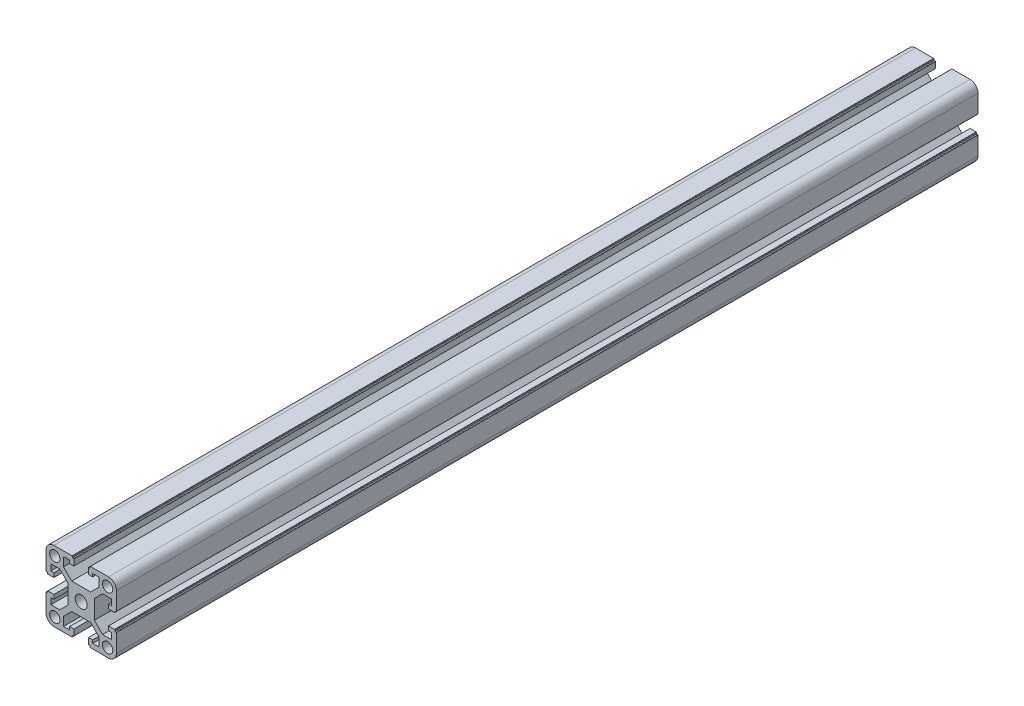
from build123d import *

# Parameters (mm, degrees)
SKETCH_1_R          = 2.95
SKETCH_1_R_2        = 3.4
EXTRUDE_1_DEPTH     = 245
SKETCH_2_R          = 4
CUT_EXTRUDE_1_DEPTH = 49


with BuildPart() as part:
    # 草图1 → 凸台-拉伸1 (new body, symmetric)
    with BuildSketch(Plane.XY.offset(100)):
        with BuildLine():
            Line((-1518.245004392, 3588.004280474), (-1518.245004392, 3582.975600817))
            Line((-1518.245004392, 3582.975600817), (-1522.916324736, 3578.304280474))
            Line((-1522.916324736, 3578.304280474), (-1533.673684048, 3578.304280474))
            Line((-1533.673684048, 3578.304280474), (-1538.345004392, 3582.975600817))
            Line((-1538.345004392, 3582.975600817), (-1538.345004392, 3588.004280474))
            Line((-1538.345004392, 3588.004280474), (-1534.845004392, 3588.004280474))
            Line((-1534.845004392, 3588.004280474), (-1534.845004392, 3586.304280474))
            Line((-1534.845004392, 3586.304280474), (-1532.445004392, 3586.304280474))
            Line((-1532.445004392, 3586.304280474), (-1532.445004392, 3589.704280474))
            ThreePointArc((-1532.445004392, 3589.704280474), (-1532.503583036, 3589.84570183), (-1532.645004392, 3589.904280474))
            Line((-1532.645004392, 3589.904280474), (-1533.345004392, 3589.904280474))
            Line((-1533.345004392, 3589.904280474), (-1533.345004392, 3590.604280474))
            ThreePointArc((-1533.345004392, 3590.604280474), (-1533.403583036, 3590.74570183), (-1533.545004392, 3590.804280474))
            Line((-1533.545004392, 3590.804280474), (-1543.795004392, 3590.804280474))
            ThreePointArc((-1543.795004392, 3590.804280474), (-1546.976984907, 3589.486260989), (-1548.295004392, 3586.304280474))
            Line((-1548.295004392, 3586.304280474), (-1548.295004392, 3576.054280474))
            ThreePointArc((-1548.295004392, 3576.054280474), (-1548.236425748, 3575.912859117), (-1548.095004392, 3575.854280474))
            Line((-1548.095004392, 3575.854280474), (-1547.395004392, 3575.854280474))
            Line((-1547.395004392, 3575.854280474), (-1547.395004392, 3575.154280474))
            ThreePointArc((-1547.395004392, 3575.154280474), (-1547.336425748, 3575.012859117), (-1547.195004392, 3574.954280474))
            Line((-1547.195004392, 3574.954280474), (-1543.795004392, 3574.954280474))
            Line((-1543.795004392, 3574.954280474), (-1543.795004392, 3577.354280474))
            Line((-1543.795004392, 3577.354280474), (-1545.495004392, 3577.354280474))
            Line((-1545.495004392, 3577.354280474), (-1545.495004392, 3580.854280474))
            Line((-1545.495004392, 3580.854280474), (-1540.466324736, 3580.854280474))
            Line((-1540.466324736, 3580.854280474), (-1535.795004392, 3576.18296013))
            Line((-1535.795004392, 3576.18296013), (-1535.795004392, 3565.425600817))
            Line((-1535.795004392, 3565.425600817), (-1540.466324736, 3560.754280474))
            Line((-1540.466324736, 3560.754280474), (-1545.495004392, 3560.754280474))
            Line((-1545.495004392, 3560.754280474), (-1545.495004392, 3564.254280474))
            Line((-1545.495004392, 3564.254280474), (-1543.795004392, 3564.254280474))
            Line((-1543.795004392, 3564.254280474), (-1543.795004392, 3566.654280474))
            Line((-1543.795004392, 3566.654280474), (-1547.195004392, 3566.654280474))
            ThreePointArc((-1547.195004392, 3566.654280474), (-1547.336425748, 3566.59570183), (-1547.395004392, 3566.454280474))
            Line((-1547.395004392, 3566.454280474), (-1547.395004392, 3565.754280474))
            Line((-1547.395004392, 3565.754280474), (-1548.095004392, 3565.754280474))
            ThreePointArc((-1548.095004392, 3565.754280474), (-1548.236425748, 3565.69570183), (-1548.295004392, 3565.554280474))
            Line((-1548.295004392, 3565.554280474), (-1548.295004392, 3555.304280474))
            ThreePointArc((-1548.295004392, 3555.304280474), (-1546.976984907, 3552.122299958), (-1543.795004392, 3550.804280474))
            Line((-1543.795004392, 3550.804280474), (-1533.545004392, 3550.804280474))
            ThreePointArc((-1533.545004392, 3550.804280474), (-1533.403583036, 3550.862859117), (-1533.345004392, 3551.004280474))
            Line((-1533.345004392, 3551.004280474), (-1533.345004392, 3551.704280474))
            Line((-1533.345004392, 3551.704280474), (-1532.645004392, 3551.704280474))
            ThreePointArc((-1532.645004392, 3551.704280474), (-1532.503583036, 3551.762859117), (-1532.445004392, 3551.904280474))
            Line((-1532.445004392, 3551.904280474), (-1532.445004392, 3555.304280474))
            Line((-1532.445004392, 3555.304280474), (-1534.845004392, 3555.304280474))
            Line((-1534.845004392, 3555.304280474), (-1534.845004392, 3553.604280474))
            Line((-1534.845004392, 3553.604280474), (-1538.345004392, 3553.604280474))
            Line((-1538.345004392, 3553.604280474), (-1538.345004392, 3558.63296013))
            Line((-1538.345004392, 3558.63296013), (-1533.673684048, 3563.304280474))
            Line((-1533.673684048, 3563.304280474), (-1522.916324736, 3563.304280474))
            Line((-1522.916324736, 3563.304280474), (-1518.245004392, 3558.63296013))
            Line((-1518.245004392, 3558.63296013), (-1518.245004392, 3553.604280474))
            Line((-1518.245004392, 3553.604280474), (-1521.745004392, 3553.604280474))
            Line((-1521.745004392, 3553.604280474), (-1521.745004392, 3555.304280474))
            Line((-1521.745004392, 3555.304280474), (-1524.145004392, 3555.304280474))
            Line((-1524.145004392, 3555.304280474), (-1524.145004392, 3551.904280474))
            ThreePointArc((-1524.145004392, 3551.904280474), (-1524.086425748, 3551.762859117), (-1523.945004392, 3551.704280474))
            Line((-1523.945004392, 3551.704280474), (-1523.245004392, 3551.704280474))
            Line((-1523.245004392, 3551.704280474), (-1523.245004392, 3551.004280474))
            ThreePointArc((-1523.245004392, 3551.004280474), (-1523.186425748, 3550.862859117), (-1523.045004392, 3550.804280474))
            Line((-1523.045004392, 3550.804280474), (-1512.795004392, 3550.804280474))
            ThreePointArc((-1512.795004392, 3550.804280474), (-1509.613023877, 3552.122299958), (-1508.295004392, 3555.304280474))
            Line((-1508.295004392, 3555.304280474), (-1508.295004392, 3565.554280474))
            ThreePointArc((-1508.295004392, 3565.554280474), (-1508.353583036, 3565.69570183), (-1508.495004392, 3565.754280474))
            Line((-1508.495004392, 3565.754280474), (-1509.195004392, 3565.754280474))
            Line((-1509.195004392, 3565.754280474), (-1509.195004392, 3566.454280474))
            ThreePointArc((-1509.195004392, 3566.454280474), (-1509.253583036, 3566.59570183), (-1509.395004392, 3566.654280474))
            Line((-1509.395004392, 3566.654280474), (-1512.795004392, 3566.654280474))
            Line((-1512.795004392, 3566.654280474), (-1512.795004392, 3564.254280474))
            Line((-1512.795004392, 3564.254280474), (-1511.095004392, 3564.254280474))
            Line((-1511.095004392, 3564.254280474), (-1511.095004392, 3560.754280474))
            Line((-1511.095004392, 3560.754280474), (-1516.123684048, 3560.754280474))
            Line((-1516.123684048, 3560.754280474), (-1520.795004392, 3565.425600817))
            Line((-1520.795004392, 3565.425600817), (-1520.795004392, 3576.18296013))
            Line((-1520.795004392, 3576.18296013), (-1516.123684048, 3580.854280474))
            Line((-1516.123684048, 3580.854280474), (-1511.095004392, 3580.854280474))
            Line((-1511.095004392, 3580.854280474), (-1511.095004392, 3577.354280474))
            Line((-1511.095004392, 3577.354280474), (-1512.795004392, 3577.354280474))
            Line((-1512.795004392, 3577.354280474), (-1512.795004392, 3574.954280474))
            Line((-1512.795004392, 3574.954280474), (-1509.395004392, 3574.954280474))
            ThreePointArc((-1509.395004392, 3574.954280474), (-1509.253583036, 3575.012859117), (-1509.195004392, 3575.154280474))
            Line((-1509.195004392, 3575.154280474), (-1509.195004392, 3575.854280474))
            Line((-1509.195004392, 3575.854280474), (-1508.495004392, 3575.854280474))
            ThreePointArc((-1508.495004392, 3575.854280474), (-1508.353583036, 3575.912859117), (-1508.295004392, 3576.054280474))
            Line((-1508.295004392, 3576.054280474), (-1508.295004392, 3586.304280474))
            ThreePointArc((-1508.295004392, 3586.304280474), (-1509.613023877, 3589.486260989), (-1512.795004392, 3590.804280474))
            Line((-1512.795004392, 3590.804280474), (-1523.045004392, 3590.804280474))
            ThreePointArc((-1523.045004392, 3590.804280474), (-1523.186425748, 3590.74570183), (-1523.245004392, 3590.604280474))
            Line((-1523.245004392, 3590.604280474), (-1523.245004392, 3589.904280474))
            Line((-1523.245004392, 3589.904280474), (-1523.945004392, 3589.904280474))
            ThreePointArc((-1523.945004392, 3589.904280474), (-1524.086425748, 3589.84570183), (-1524.145004392, 3589.704280474))
            Line((-1524.145004392, 3589.704280474), (-1524.145004392, 3586.304280474))
            Line((-1524.145004392, 3586.304280474), (-1521.745004392, 3586.304280474))
            Line((-1521.745004392, 3586.304280474), (-1521.745004392, 3588.004280474))
            Line((-1521.745004392, 3588.004280474), (-1518.245004392, 3588.004280474))
        make_face()
        with Locations((-1513.270004392, 3555.779280474)):
            Circle(SKETCH_1_R, mode=Mode.SUBTRACT)
        with Locations((-1528.295004392, 3570.804280474)):
            Circle(SKETCH_1_R_2, mode=Mode.SUBTRACT)
        with Locations((-1513.270004392, 3585.829280474)):
            Circle(SKETCH_1_R, mode=Mode.SUBTRACT)
        with Locations((-1543.320004392, 3585.829280474)):
            Circle(SKETCH_1_R, mode=Mode.SUBTRACT)
        with Locations((-1543.320004392, 3555.779280474)):
            Circle(SKETCH_1_R, mode=Mode.SUBTRACT)
    extrude(amount=EXTRUDE_1_DEPTH, both=True)

    # 草图2 → 切除-拉伸1 (cut)
    with BuildSketch(Plane(origin=(0, 3578.304280474, 0), x_dir=(1, 0, 0), z_dir=(0, 1, 0))):
        with Locations((-1528.295004392, 15)):
            Circle(SKETCH_2_R)
        with Locations((-1528.295004392, -215)):
            Circle(SKETCH_2_R)
    extrude(amount=-CUT_EXTRUDE_1_DEPTH, mode=Mode.SUBTRACT)


solid = part.part
